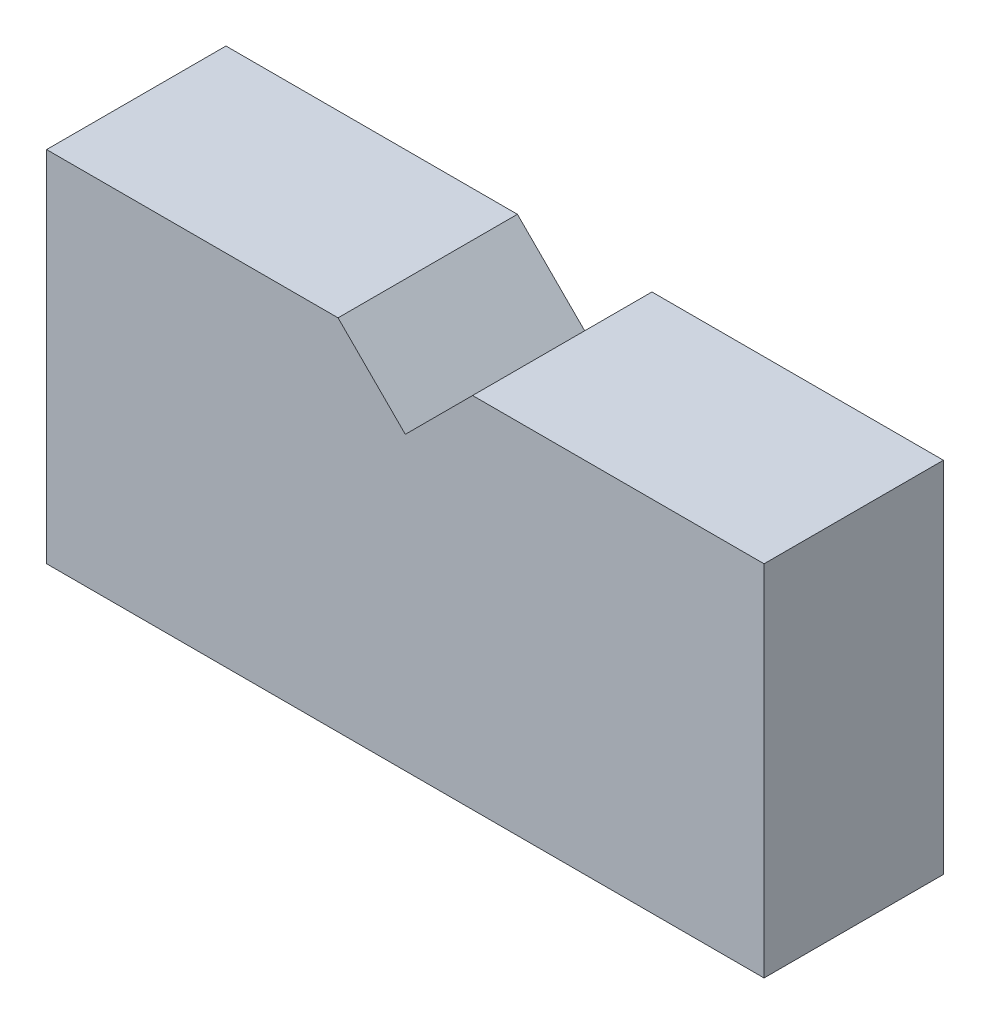
from build123d import *

# Parameters (mm, degrees)
BOSS_EXTRUDE2_DEPTH = 25.4


with BuildPart() as part:
    # Sketch3 → Boss-Extrude2 (new body, symmetric)
    with BuildSketch(Plane.XY):
        Polygon((82.55, 101.6), (101.6, 82.55), (120.65, 101.6), (203.2, 101.6), (203.2, 0), (0, 0), (0, 101.6), align=None)
    extrude(amount=BOSS_EXTRUDE2_DEPTH, both=True)


solid = part.part
